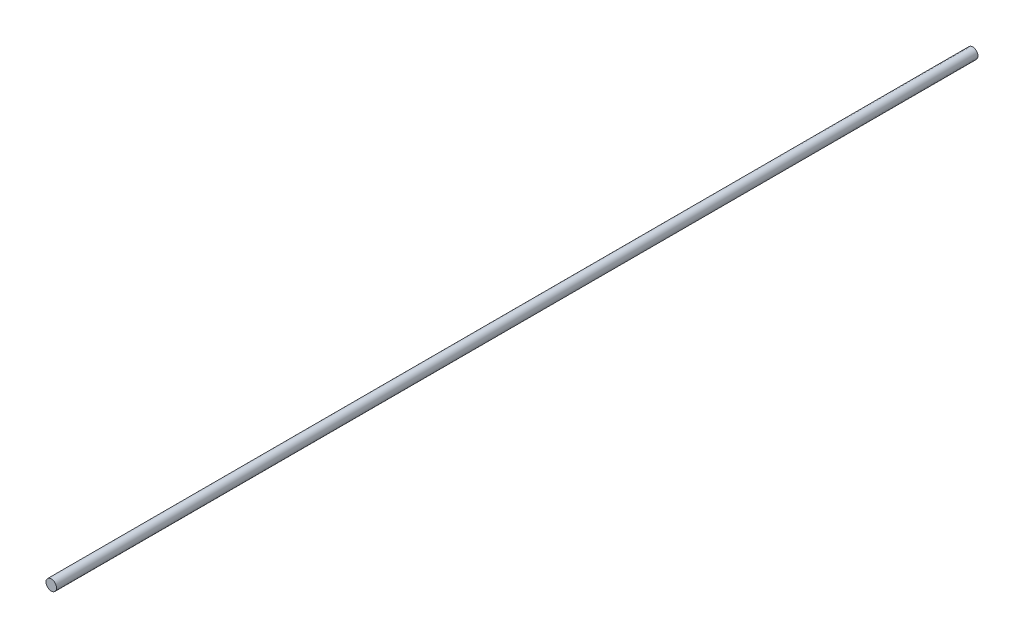
from build123d import *

# Parameters (mm, degrees)
SKETCH1_R           = 0.254
BOSS_EXTRUDE1_DEPTH = 22.225


with BuildPart() as part:
    # Sketch1 → Boss-Extrude1 (new body, symmetric)
    with BuildSketch(Plane.XY):
        Circle(SKETCH1_R)
    extrude(amount=BOSS_EXTRUDE1_DEPTH, both=True)


solid = part.part
